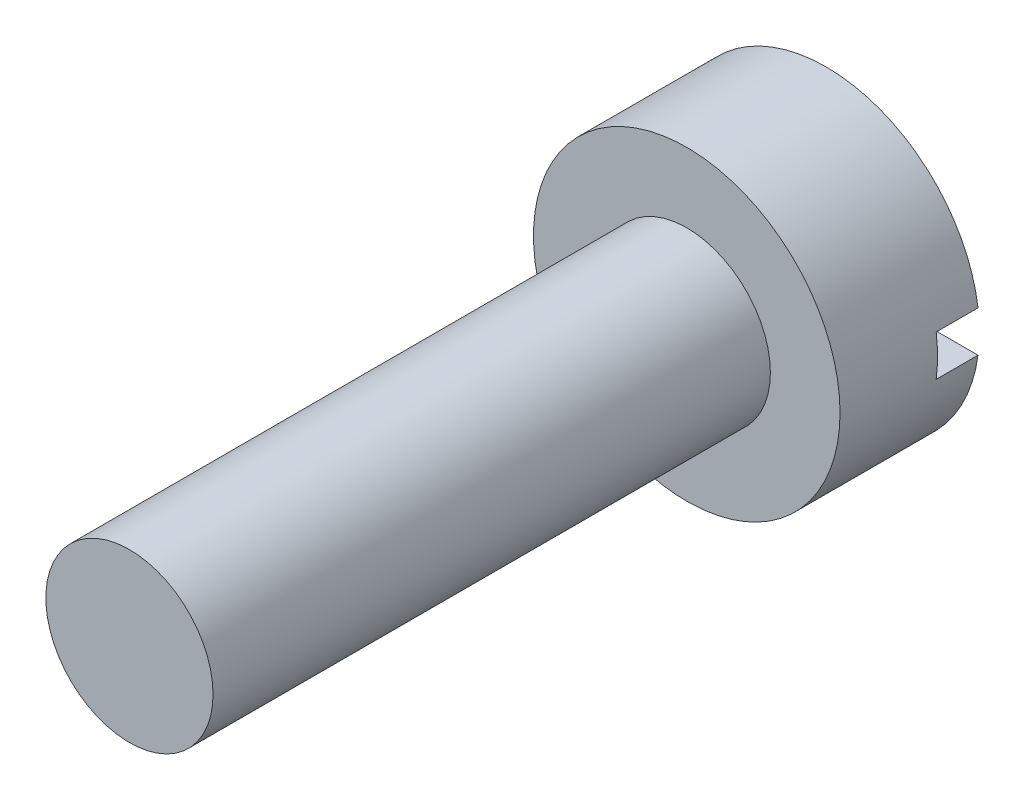
from build123d import *

# Parameters (mm, degrees)
ESQUISSE1_R             = 2.75
BOSS_EXTRU_1_DEPTH      = 2.5
ESQUISSE2_R             = 1.5
BOSS_EXTRU_2_DEPTH      = 10
ESQUISSE3_W             = 7.386684128
ESQUISSE3_H             = 0.735038592
ENL_V_MAT_EXTRU_1_DEPTH = 0.75


with BuildPart() as part:
    # Esquisse1 → Boss.-Extru.1 (new body)
    with BuildSketch(Plane.XY):
        Circle(ESQUISSE1_R)
    extrude(amount=BOSS_EXTRU_1_DEPTH)

    # Esquisse2 → Boss.-Extru.2 (add)
    with BuildSketch(Plane.XY.offset(2.5)):
        Circle(ESQUISSE2_R)
    extrude(amount=BOSS_EXTRU_2_DEPTH)

    # Esquisse3 → Enlèv. mat.-Extru.1 (cut)
    with BuildSketch(Plane(origin=(0, 0, 0), x_dir=(-1, 0, 0), z_dir=(0, 0, -1))):
        Rectangle(ESQUISSE3_W, ESQUISSE3_H)
    extrude(amount=-ENL_V_MAT_EXTRU_1_DEPTH, mode=Mode.SUBTRACT)


solid = part.part
